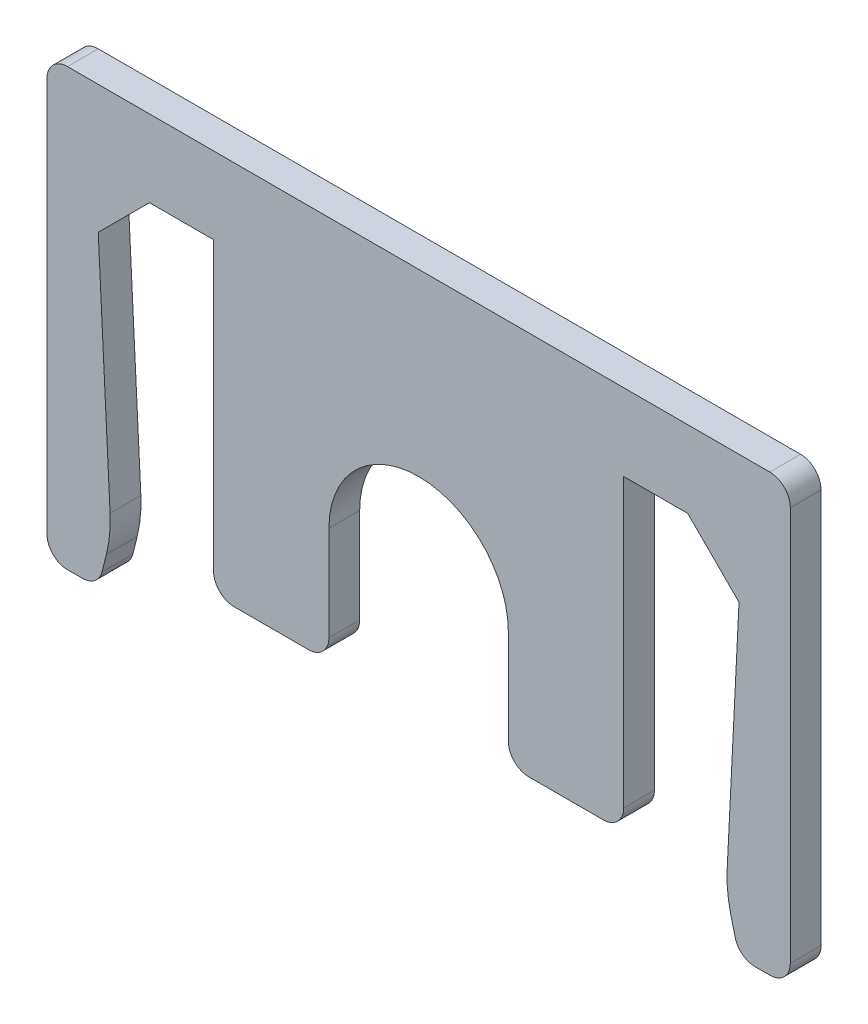
from build123d import *

# Parameters (mm, degrees)
BOSS_EXTRUDE1_DEPTH = 1.2
FILLET1_R           = 5
FILLET2_R           = 0.8


with BuildPart() as part:
    # Sketch1 → Boss-Extrude1 (new body)
    with BuildSketch(Plane.XY):
        with BuildLine():
            Line((-10.5, 0), (-12.5, -2))
            Line((-12.5, -2), (-12, -12))
            Line((-12, -12), (-12.5, -14))
            Line((-12.5, -14), (-14.5, -14))
            Line((-14.5, -14), (-14.5, 3))
            Line((-14.5, 3), (-12.5, 3))
            Line((-12.5, 3), (12.5, 3))
            Line((12.5, 3), (14.5, 3))
            Line((14.5, 3), (14.5, -14))
            Line((14.5, -14), (12.5, -14))
            Line((12.5, -14), (12, -12))
            Line((12, -12), (12.5, -2))
            Line((12.5, -2), (10.5, 0))
            Line((10.5, 0), (8, 0))
            Line((8, 0), (8, -12))
            Line((8, -12), (3.5, -12))
            Line((3.5, -12), (3.5, -7.5))
            ThreePointArc((3.5, -7.5), (0, -4), (-3.5, -7.5))
            Line((-3.5, -7.5), (-3.5, -12))
            Line((-3.5, -12), (-8, -12))
            Line((-8, -12), (-8, 0))
            Line((-8, 0), (-10.5, 0))
        make_face()
    extrude(amount=BOSS_EXTRUDE1_DEPTH)

    # Fillet1
    fillet1_edges = [part.edges().sort_by_distance(p)[0] for p in [
        (-12, -12, 0.6),
        (12, -12, 0.6),
    ]]
    fillet(fillet1_edges, radius=FILLET1_R)

    # Fillet2
    fillet2_edges = [part.edges().sort_by_distance(p)[0] for p in [
        (-12.5, -14, 0.6),
        (-14.5, -14, 0.6),
        (-14.5, 3, 0.6),
        (14.5, 3, 0.6),
        (14.5, -14, 0.6),
        (12.5, -14, 0.6),
        (8, -12, 0.6),
        (3.5, -12, 0.6),
        (-3.5, -12, 0.6),
        (-8, -12, 0.6),
    ]]
    fillet(fillet2_edges, radius=FILLET2_R)


solid = part.part
